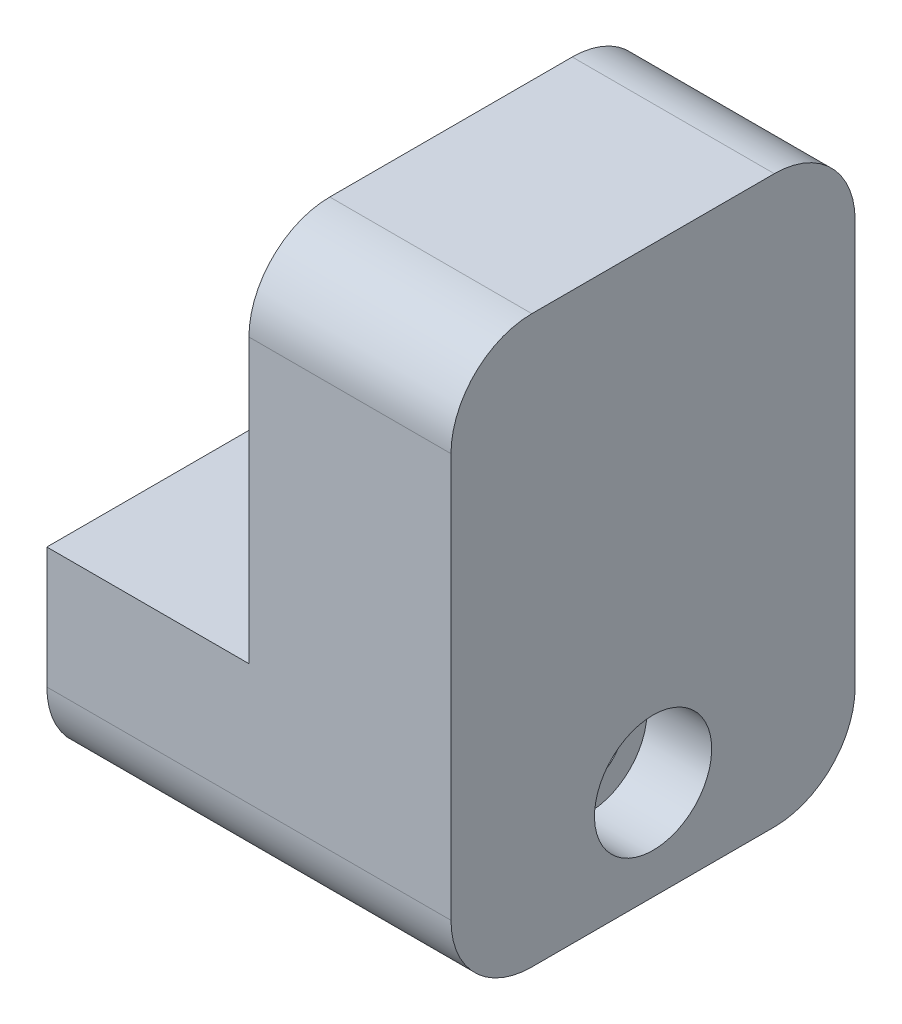
from build123d import *

# Parameters (mm, degrees)
PROFILE_W               = 12.7
PROFILE_H               = 22.86
PROFILE_W_2             = 6.35
PROFILE_H_2             = 12.7
BOSS_EXTRUDE1_DEPTH     = 12.7
SKETCH7_W               = 19.05
SKETCH7_H               = 12.7
BOSS_EXTRUDE2_DEPTH     = 25.4
SCREWHOLE_R             = 2.159
CUT_EXTRUDE1_DEPTH      = 1
CUT_EXTRUDE1_DEPTH_BACK = 26.4
SKETCH3_R               = 3.683
SKETCH3_R_2             = 2.159
CUT_EXTRUDE2_DEPTH      = 4.064
SKETCH10_R              = 1.143
CUT_EXTRUDE3_DEPTH      = 7.62
FILLET6_R               = 5.08


with BuildPart() as part:
    # Profile → Boss-Extrude1 (new body, symmetric)
    with BuildSketch(Plane.XY):
        with Locations((0, 11.43)):
            Rectangle(PROFILE_W, PROFILE_H)
        with Locations((3.175, -6.35)):
            Rectangle(PROFILE_W_2, PROFILE_H_2)
    extrude(amount=BOSS_EXTRUDE1_DEPTH, both=True)

    # Sketch7 → Boss-Extrude2 (add)
    with BuildSketch(Plane.XY.offset(12.7)):
        with Locations((-9.525, -6.35)):
            Rectangle(SKETCH7_W, SKETCH7_H)
    extrude(amount=-BOSS_EXTRUDE2_DEPTH)

    # ScrewHole → Cut-Extrude1 (cut, two sides)
    with BuildSketch(Plane.ZY.offset(19.05)) as cut_extrude1_sk:
        with Locations((0, -6.477)):
            Circle(SCREWHOLE_R)
    extrude(amount=CUT_EXTRUDE1_DEPTH, mode=Mode.SUBTRACT)
    extrude(cut_extrude1_sk.sketch, amount=-CUT_EXTRUDE1_DEPTH_BACK, mode=Mode.SUBTRACT)

    # Sketch3 → Cut-Extrude2 (cut)
    with BuildSketch(Plane(origin=(6.35, 0, 0), x_dir=(0, 0, -1), z_dir=(1, 0, 0))):
        with Locations((0, -6.477)):
            Circle(SKETCH3_R)
        with Locations((0, -6.477)):
            Circle(SKETCH3_R_2, mode=Mode.SUBTRACT)
    extrude(amount=-CUT_EXTRUDE2_DEPTH, mode=Mode.SUBTRACT)

    # Sketch10 → Cut-Extrude3 (cut)
    with BuildSketch(Plane.ZY.offset(6.35)):
        with Locations((-10.16, 17.78)):
            Circle(SKETCH10_R)
        with Locations((10.16, 17.78)):
            Circle(SKETCH10_R)
        with Locations((10.16, 5.08)):
            Circle(SKETCH10_R)
        with Locations((-10.16, 5.08)):
            Circle(SKETCH10_R)
    extrude(amount=-CUT_EXTRUDE3_DEPTH, mode=Mode.SUBTRACT)

    # Fillet6
    fillet6_edges = [part.edges().sort_by_distance(p)[0] for p in [
        (0, 22.86, -12.7),
        (0, 22.86, 12.7),
        (-6.35, -12.7, 12.7),
        (-6.35, -12.7, -12.7),
    ]]
    fillet(fillet6_edges, radius=FILLET6_R)


solid = part.part
